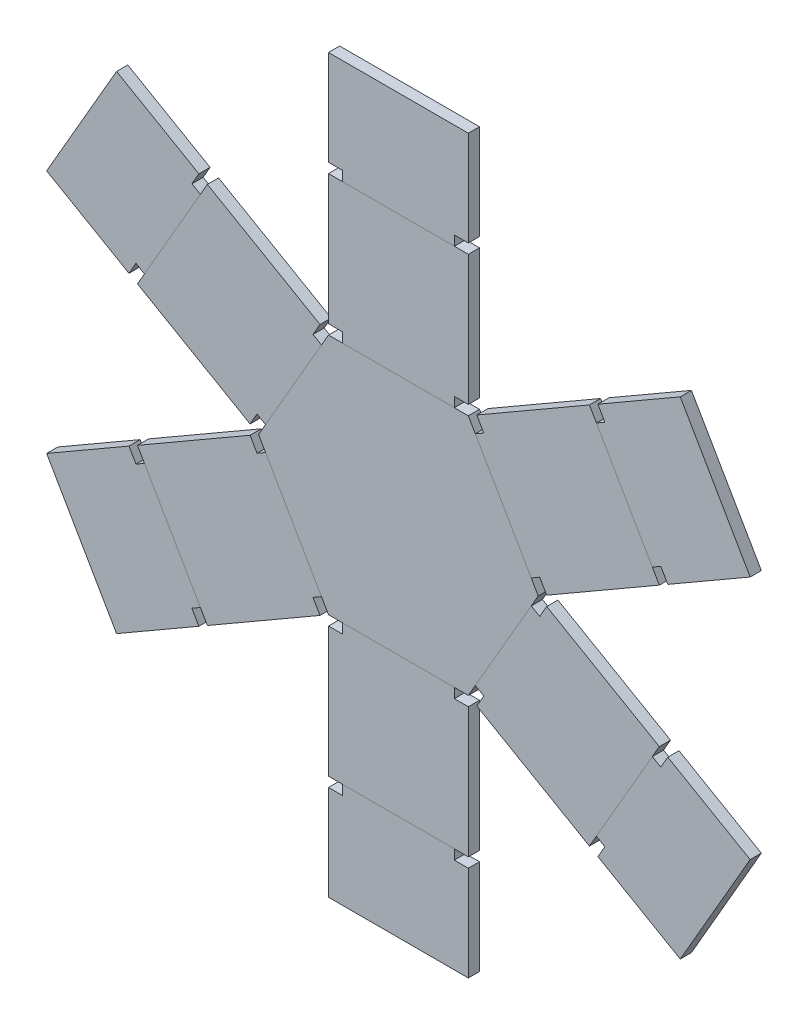
from build123d import *

# Parameters (mm, degrees)
BOSS_EXTRUDE1_DEPTH   = 0.08
BOSS_EXTRUDE3_DEPTH   = 0.08
BOSS_EXTRUDE3_2_DEPTH = 0.08
BOSS_EXTRUDE3_3_DEPTH = 0.08
BOSS_EXTRUDE3_4_DEPTH = 0.08
BOSS_EXTRUDE3_5_DEPTH = 0.08
BOSS_EXTRUDE3_6_DEPTH = 0.08
BOSS_EXTRUDE4_DEPTH   = 0.08
BOSS_EXTRUDE4_2_DEPTH = 0.08
BOSS_EXTRUDE4_3_DEPTH = 0.08
BOSS_EXTRUDE4_4_DEPTH = 0.08
BOSS_EXTRUDE4_5_DEPTH = 0.08
BOSS_EXTRUDE4_6_DEPTH = 0.08


with BuildPart() as part:
    # Sketch1 → Boss-Extrude1 (new body)
    with BuildSketch(Plane.XY):
        Polygon((-1, 0), (-0.5, -0.866025404), (0.5, -0.866025404), (1, 0), (0.5, 0.866025404), (-0.5, 0.866025404), align=None)
    extrude(amount=BOSS_EXTRUDE1_DEPTH)


with BuildPart() as body_2:
    # Sketch2 → Boss-Extrude3 (new body)
    with BuildSketch(Plane.XY.offset(0.08)):
        Polygon((-1.010621778, 0.12160254), (-0.95, 0.08660254), (-0.55, 0.779422863), (-0.610621778, 0.814422863), (-0.560621778, 0.901025404), (-1.366025404, 1.366025404), (-1.866025404, 0.5), (-1.060621778, 0.035), align=None)
    extrude(amount=-BOSS_EXTRUDE3_DEPTH)


with BuildPart() as body_3:
    # Sketch2 → Boss-Extrude3 2 (new body)
    with BuildSketch(Plane.XY.offset(0.08)):
        Polygon((-0.4, 0.936025404), (-0.4, 0.866025404), (0.4, 0.866025404), (0.4, 0.936025404), (0.5, 0.936025404), (0.5, 1.866025404), (-0.5, 1.866025404), (-0.5, 0.936025404), align=None)
    extrude(amount=-BOSS_EXTRUDE3_2_DEPTH)


with BuildPart() as body_4:
    # Sketch2 → Boss-Extrude3 3 (new body)
    with BuildSketch(Plane.XY.offset(0.08)):
        Polygon((0.610621778, 0.814422863), (0.55, 0.779422863), (0.95, 0.08660254), (1.010621778, 0.12160254), (1.060621778, 0.035), (1.866025404, 0.5), (1.366025404, 1.366025404), (0.560621778, 0.901025404), align=None)
    extrude(amount=-BOSS_EXTRUDE3_3_DEPTH)


with BuildPart() as body_5:
    # Sketch2 → Boss-Extrude3 4 (new body)
    with BuildSketch(Plane.XY.offset(0.08)):
        Polygon((1.010621778, -0.12160254), (0.95, -0.08660254), (0.55, -0.779422863), (0.610621778, -0.814422863), (0.560621778, -0.901025404), (1.366025404, -1.366025404), (1.866025404, -0.5), (1.060621778, -0.035), align=None)
    extrude(amount=-BOSS_EXTRUDE3_4_DEPTH)


with BuildPart() as body_6:
    # Sketch2 → Boss-Extrude3 5 (new body)
    with BuildSketch(Plane.XY.offset(0.08)):
        Polygon((0.4, -0.936025404), (0.4, -0.866025404), (-0.4, -0.866025404), (-0.4, -0.936025404), (-0.5, -0.936025404), (-0.5, -1.866025404), (0.5, -1.866025404), (0.5, -0.936025404), align=None)
    extrude(amount=-BOSS_EXTRUDE3_5_DEPTH)


with BuildPart() as body_7:
    # Sketch2 → Boss-Extrude3 6 (new body)
    with BuildSketch(Plane.XY.offset(0.08)):
        Polygon((-0.610621778, -0.814422863), (-0.55, -0.779422863), (-0.95, -0.08660254), (-1.010621778, -0.12160254), (-1.060621778, -0.035), (-1.866025404, -0.5), (-1.366025404, -1.366025404), (-0.560621778, -0.901025404), align=None)
    extrude(amount=-BOSS_EXTRUDE3_6_DEPTH)


with BuildPart() as body_8:
    # Sketch3 → Boss-Extrude4 (new body)
    with BuildSketch(Plane.XY.offset(0.08)):
        Polygon((-1.416025404, 1.279422863), (-1.816025404, 0.58660254), (-1.876647182, 0.62160254), (-1.926647182, 0.535), (-2.515544457, 0.875), (-2.015544457, 1.741025404), (-1.426647182, 1.401025404), (-1.476647182, 1.314422863), align=None)
    extrude(amount=-BOSS_EXTRUDE4_DEPTH)


with BuildPart() as body_9:
    # Sketch3 → Boss-Extrude4 2 (new body)
    with BuildSketch(Plane.XY.offset(0.08)):
        Polygon((0.4, 1.866025404), (-0.4, 1.866025404), (-0.4, 1.936025404), (-0.5, 1.936025404), (-0.5, 2.616025404), (0.5, 2.616025404), (0.5, 1.936025404), (0.4, 1.936025404), align=None)
    extrude(amount=-BOSS_EXTRUDE4_2_DEPTH)


with BuildPart() as body_10:
    # Sketch3 → Boss-Extrude4 3 (new body)
    with BuildSketch(Plane.XY.offset(0.08)):
        Polygon((1.816025404, 0.58660254), (1.416025404, 1.279422863), (1.476647182, 1.314422863), (1.426647182, 1.401025404), (2.015544457, 1.741025404), (2.515544457, 0.875), (1.926647182, 0.535), (1.876647182, 0.62160254), align=None)
    extrude(amount=-BOSS_EXTRUDE4_3_DEPTH)


with BuildPart() as body_11:
    # Sketch3 → Boss-Extrude4 4 (new body)
    with BuildSketch(Plane.XY.offset(0.08)):
        Polygon((1.416025404, -1.279422863), (1.816025404, -0.58660254), (1.876647182, -0.62160254), (1.926647182, -0.535), (2.515544457, -0.875), (2.015544457, -1.741025404), (1.426647182, -1.401025404), (1.476647182, -1.314422863), align=None)
    extrude(amount=-BOSS_EXTRUDE4_4_DEPTH)


with BuildPart() as body_12:
    # Sketch3 → Boss-Extrude4 5 (new body)
    with BuildSketch(Plane.XY.offset(0.08)):
        Polygon((-0.4, -1.866025404), (0.4, -1.866025404), (0.4, -1.936025404), (0.5, -1.936025404), (0.5, -2.616025404), (-0.5, -2.616025404), (-0.5, -1.936025404), (-0.4, -1.936025404), align=None)
    extrude(amount=-BOSS_EXTRUDE4_5_DEPTH)


with BuildPart() as body_13:
    # Sketch3 → Boss-Extrude4 6 (new body)
    with BuildSketch(Plane.XY.offset(0.08)):
        Polygon((-1.816025404, -0.58660254), (-1.416025404, -1.279422863), (-1.476647182, -1.314422863), (-1.426647182, -1.401025404), (-2.015544457, -1.741025404), (-2.515544457, -0.875), (-1.926647182, -0.535), (-1.876647182, -0.62160254), align=None)
    extrude(amount=-BOSS_EXTRUDE4_6_DEPTH)


solid = Compound([part.part, body_2.part, body_3.part, body_4.part, body_5.part, body_6.part, body_7.part, body_8.part, body_9.part, body_10.part, body_11.part, body_12.part, body_13.part])
